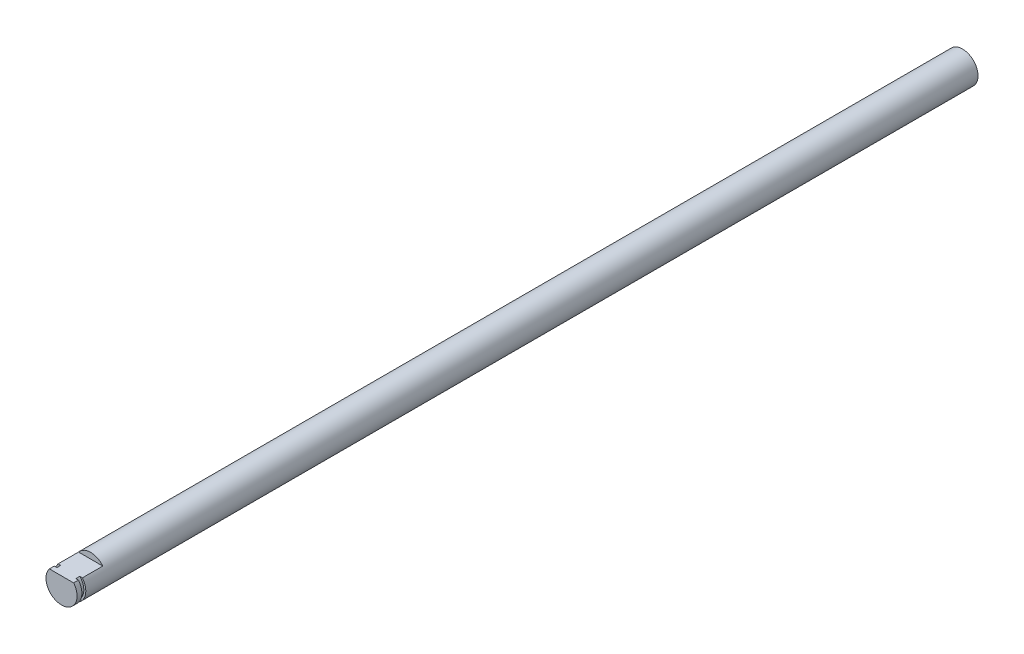
from build123d import *

# Parameters (mm, degrees)
SKETCH1_R           = 4
BOSS_EXTRUDE1_DEPTH = 325
CUT_EXTRUDE1_DEPTH  = 7.5
SKETCH3_R           = 4
SKETCH3_R_2         = 3.5
CUT_EXTRUDE2_DEPTH  = 1
SKETCH5_R           = 4
CUT_EXTRUDE3_DEPTH  = 65
SKETCH6_R           = 4
BOSS_EXTRUDE2_DEPTH = 13
SKETCH7_R           = 4
BOSS_EXTRUDE3_DEPTH = 10
SKETCH8_R           = 4
BOSS_EXTRUDE4_DEPTH = 40
SKETCH9_R           = 4
CUT_EXTRUDE4_DEPTH  = 30
SKETCH10_R          = 4
CUT_EXTRUDE5_DEPTH  = 61


with BuildPart() as part:
    # Sketch1 → Boss-Extrude1 (new body)
    with BuildSketch(Plane.XY):
        Circle(SKETCH1_R)
    extrude(amount=BOSS_EXTRUDE1_DEPTH)

    # Sketch2 → Cut-Extrude1 (cut)
    with BuildSketch(Plane.XY.offset(325)):
        with BuildLine():
            Line((3.122498999, 2.5), (-3.122498999, 2.5))
            ThreePointArc((-3.122498999, 2.5), (0, 4), (3.122498999, 2.5))
        make_face()
    extrude(amount=-CUT_EXTRUDE1_DEPTH, mode=Mode.SUBTRACT)

    # Sketch3 → Cut-Extrude2 (cut)
    with BuildSketch(Plane.XY.offset(323.75)):
        Circle(SKETCH3_R)
        Circle(SKETCH3_R_2, mode=Mode.SUBTRACT)
    extrude(amount=-CUT_EXTRUDE2_DEPTH, mode=Mode.SUBTRACT)

    # Sketch5 → Cut-Extrude3 (cut)
    with BuildSketch(Plane(origin=(0, 0, 0), x_dir=(-1, 0, 0), z_dir=(0, 0, -1))):
        Circle(SKETCH5_R)
    extrude(amount=-CUT_EXTRUDE3_DEPTH, mode=Mode.SUBTRACT)

    # Sketch6 → Boss-Extrude2 (add)
    with BuildSketch(Plane(origin=(0, 0, 65), x_dir=(-1, 0, 0), z_dir=(0, 0, -1))):
        Circle(SKETCH6_R)
    extrude(amount=BOSS_EXTRUDE2_DEPTH)

    # Sketch7 → Boss-Extrude3 (add)
    with BuildSketch(Plane(origin=(0, 0, 52), x_dir=(-1, 0, 0), z_dir=(0, 0, -1))):
        Circle(SKETCH7_R)
    extrude(amount=BOSS_EXTRUDE3_DEPTH)

    # Sketch8 → Boss-Extrude4 (add)
    with BuildSketch(Plane(origin=(0, 0, 42), x_dir=(-1, 0, 0), z_dir=(0, 0, -1))):
        Circle(SKETCH8_R)
    extrude(amount=BOSS_EXTRUDE4_DEPTH)

    # Sketch9 → Cut-Extrude4 (cut)
    with BuildSketch(Plane(origin=(0, 0, 2), x_dir=(-1, 0, 0), z_dir=(0, 0, -1))):
        Circle(SKETCH9_R)
    extrude(amount=-CUT_EXTRUDE4_DEPTH, mode=Mode.SUBTRACT)

    # Sketch10 → Cut-Extrude5 (cut)
    with BuildSketch(Plane(origin=(0, 0, 32), x_dir=(-1, 0, 0), z_dir=(0, 0, -1))):
        Circle(SKETCH10_R)
    extrude(amount=-CUT_EXTRUDE5_DEPTH, mode=Mode.SUBTRACT)


solid = part.part
